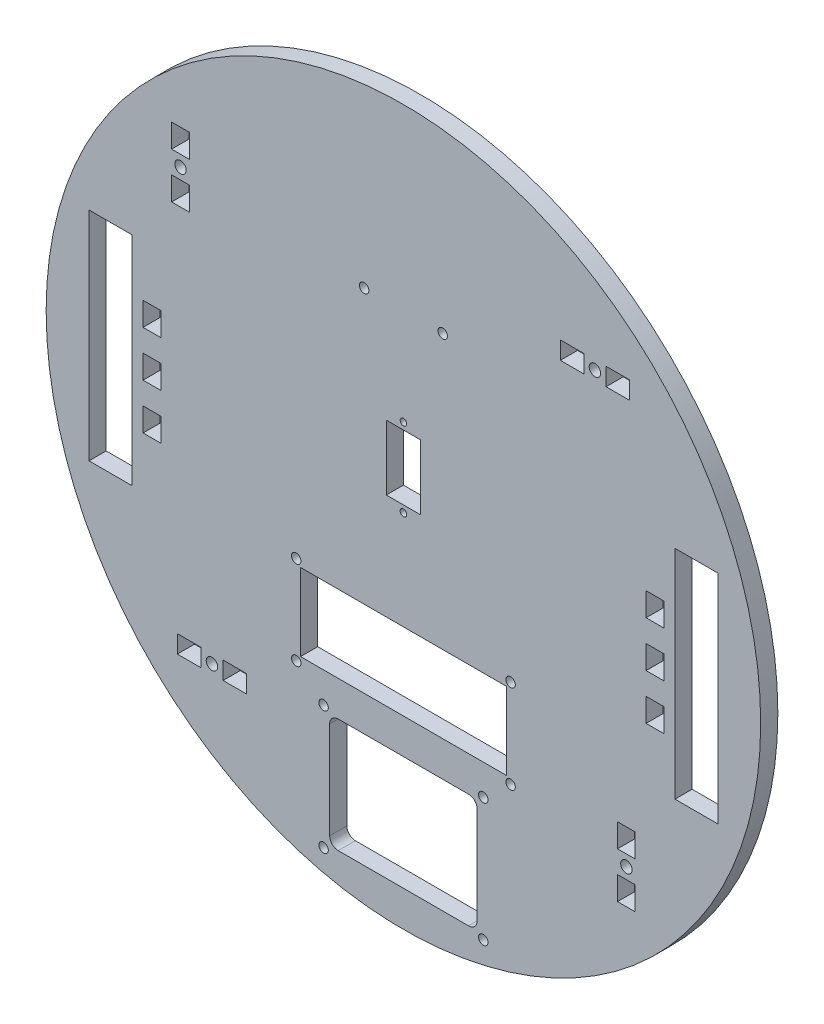
from build123d import *

# Parameters (mm, degrees)
ESQUISSE1_R                  = 125
BOSS_EXTRU_1_DEPTH           = 6
ESQUISSE2_W                  = 15
ESQUISSE2_H                  = 76
ENL_V_MAT_EXTRU_1_DEPTH      = 177.878489365
ESQUISSE3_R                  = 2
ESQUISSE3_W                  = 8.2
ESQUISSE3_H                  = 6.2
ENL_V_MAT_EXTRU_2_DEPTH      = 177.878489365
R_P_TITION_CIRCULAIRE1_COUNT = 4
ESQUISSE4_W                  = 6.2
ESQUISSE4_H                  = 8.2
ENL_V_MAT_EXTRU_3_DEPTH      = 177.878489365
ENL_V_MAT_EXTRU_4_REACH      = 178.878
ESQUISSE8_R                  = 1.65
ESQUISSE8_W                  = 72
ESQUISSE8_H                  = 27
ENL_V_MAT_EXTRU_5_REACH      = 178.878
ESQUISSE9_R                  = 1.65
ESQUISSE9_R_2                = 1.15
ESQUISSE9_W                  = 12
ESQUISSE9_H                  = 22.7


with BuildPart() as part:
    # Esquisse1 → Boss.-Extru.1 (new body)
    with BuildSketch(Plane.XY):
        Circle(ESQUISSE1_R)
    extrude(amount=BOSS_EXTRU_1_DEPTH)

    # Esquisse2 → Enlèv. mat.-Extru.1 (cut, through all)
    with BuildSketch(Plane.XY.offset(6)):
        with Locations((-102.5, 0)):
            Rectangle(ESQUISSE2_W, ESQUISSE2_H)
    enl_v_mat_extru_1 = extrude(amount=-ENL_V_MAT_EXTRU_1_DEPTH, mode=Mode.SUBTRACT)

    # Symétrie1: Enlèv. mat.-Extru.1 across plane
    add(enl_v_mat_extru_1.mirror(Plane(origin=(0, 0, 0), x_dir=(0, 0, 1), z_dir=(1, 0, 0))), mode=Mode.SUBTRACT)

    # Esquisse3 → Enlèv. mat.-Extru.2 (cut, through all)
    with BuildSketch(Plane(origin=(0, 0, 0), x_dir=(-1, 0, 0), z_dir=(0, 0, -1))):
        with Locations((-67, 78)):
            Circle(ESQUISSE3_R)
        with Locations((-75, 78)):
            Rectangle(ESQUISSE3_W, ESQUISSE3_H)
        with Locations((-59, 78)):
            Rectangle(ESQUISSE3_W, ESQUISSE3_H)
    enl_v_mat_extru_2 = extrude(amount=-ENL_V_MAT_EXTRU_2_DEPTH, mode=Mode.SUBTRACT)

    # Répétition circulaire1: Enlèv. mat.-Extru.2 ×4 about axis
    r_p_tition_circulaire1_axis = Axis((0, 0, -0.25), (0, 0, 1))
    for i in range(1, R_P_TITION_CIRCULAIRE1_COUNT):
        add(enl_v_mat_extru_2.rotate(r_p_tition_circulaire1_axis, i * 360 / R_P_TITION_CIRCULAIRE1_COUNT), mode=Mode.SUBTRACT)

    # Esquisse4 → Enlèv. mat.-Extru.3 (cut, through all)
    with BuildSketch(Plane(origin=(0, 0, 0), x_dir=(-1, 0, 0), z_dir=(0, 0, -1))):
        with Locations((88, 16)):
            Rectangle(ESQUISSE4_W, ESQUISSE4_H)
        with Locations((88, -16)):
            Rectangle(ESQUISSE4_W, ESQUISSE4_H)
        with Locations((88, 0)):
            Rectangle(ESQUISSE4_W, ESQUISSE4_H)
    enl_v_mat_extru_3 = extrude(amount=-ENL_V_MAT_EXTRU_3_DEPTH, mode=Mode.SUBTRACT)

    # Symétrie2: Enlèv. mat.-Extru.3 across plane
    add(enl_v_mat_extru_3.mirror(Plane(origin=(0, 0, 0), x_dir=(0, 0, 1), z_dir=(1, 0, 0))), mode=Mode.SUBTRACT)

    # Esquisse8 → Enlèv. mat.-Extru.4 (cut, up to next)
    with BuildSketch(Plane.XY.offset(6), mode=Mode.PRIVATE) as enl_v_mat_extru_4_sk1:
        with Locations((-37.5, -31.305965203)):
            Circle(ESQUISSE8_R)
    enl_v_mat_extru_4_tool1 = extrude(enl_v_mat_extru_4_sk1.sketch, amount=-ENL_V_MAT_EXTRU_4_REACH, mode=Mode.PRIVATE) & part.part
    # Esquisse8 → Enlèv. mat.-Extru.4 (cut, up to next)
    with BuildSketch(Plane.XY.offset(6), mode=Mode.PRIVATE) as enl_v_mat_extru_4_sk2:
        with Locations((37.5, -31.305965203)):
            Circle(ESQUISSE8_R)
    enl_v_mat_extru_4_tool2 = extrude(enl_v_mat_extru_4_sk2.sketch, amount=-ENL_V_MAT_EXTRU_4_REACH, mode=Mode.PRIVATE) & part.part
    # Esquisse8 → Enlèv. mat.-Extru.4 (cut, up to next)
    with BuildSketch(Plane.XY.offset(6), mode=Mode.PRIVATE) as enl_v_mat_extru_4_sk3:
        with Locations((37.5, -62.305965203)):
            Circle(ESQUISSE8_R)
    enl_v_mat_extru_4_tool3 = extrude(enl_v_mat_extru_4_sk3.sketch, amount=-ENL_V_MAT_EXTRU_4_REACH, mode=Mode.PRIVATE) & part.part
    # Esquisse8 → Enlèv. mat.-Extru.4 (cut, up to next)
    with BuildSketch(Plane.XY.offset(6), mode=Mode.PRIVATE) as enl_v_mat_extru_4_sk4:
        with Locations((-37.5, -62.305965203)):
            Circle(ESQUISSE8_R)
    enl_v_mat_extru_4_tool4 = extrude(enl_v_mat_extru_4_sk4.sketch, amount=-ENL_V_MAT_EXTRU_4_REACH, mode=Mode.PRIVATE) & part.part
    # Esquisse8 → Enlèv. mat.-Extru.4 (cut, up to next)
    with BuildSketch(Plane.XY.offset(6), mode=Mode.PRIVATE) as enl_v_mat_extru_4_sk5:
        with Locations((-27.94, -70.967629177)):
            Circle(ESQUISSE8_R)
    enl_v_mat_extru_4_tool5 = extrude(enl_v_mat_extru_4_sk5.sketch, amount=-ENL_V_MAT_EXTRU_4_REACH, mode=Mode.PRIVATE) & part.part
    # Esquisse8 → Enlèv. mat.-Extru.4 (cut, up to next)
    with BuildSketch(Plane.XY.offset(6), mode=Mode.PRIVATE) as enl_v_mat_extru_4_sk6:
        with Locations((27.94, -70.967629177)):
            Circle(ESQUISSE8_R)
    enl_v_mat_extru_4_tool6 = extrude(enl_v_mat_extru_4_sk6.sketch, amount=-ENL_V_MAT_EXTRU_4_REACH, mode=Mode.PRIVATE) & part.part
    # Esquisse8 → Enlèv. mat.-Extru.4 (cut, up to next)
    with BuildSketch(Plane.XY.offset(6), mode=Mode.PRIVATE) as enl_v_mat_extru_4_sk7:
        with Locations((27.94, -114.147629177)):
            Circle(ESQUISSE8_R)
    enl_v_mat_extru_4_tool7 = extrude(enl_v_mat_extru_4_sk7.sketch, amount=-ENL_V_MAT_EXTRU_4_REACH, mode=Mode.PRIVATE) & part.part
    # Esquisse8 → Enlèv. mat.-Extru.4 (cut, up to next)
    with BuildSketch(Plane.XY.offset(6), mode=Mode.PRIVATE) as enl_v_mat_extru_4_sk8:
        with Locations((-27.94, -114.147629177)):
            Circle(ESQUISSE8_R)
    enl_v_mat_extru_4_tool8 = extrude(enl_v_mat_extru_4_sk8.sketch, amount=-ENL_V_MAT_EXTRU_4_REACH, mode=Mode.PRIVATE) & part.part
    # Esquisse8 → Enlèv. mat.-Extru.4 (cut, up to next)
    with BuildSketch(Plane.XY.offset(6), mode=Mode.PRIVATE) as enl_v_mat_extru_4_sk9:
        with Locations((0, -46.805965203)):
            Rectangle(ESQUISSE8_W, ESQUISSE8_H)
    enl_v_mat_extru_4_tool9 = extrude(enl_v_mat_extru_4_sk9.sketch, amount=-ENL_V_MAT_EXTRU_4_REACH, mode=Mode.PRIVATE) & part.part
    # Esquisse8 → Enlèv. mat.-Extru.4 (cut, up to next)
    with BuildSketch(Plane.XY.offset(6), mode=Mode.PRIVATE) as enl_v_mat_extru_4_sk10:
        with BuildLine():
            Line((-22.804705882, -112.497629177), (22.804705882, -112.497629177))
            ThreePointArc((22.804705882, -112.497629177), (24.926026226, -111.618949521), (25.804705882, -109.497629177))
            Line((25.804705882, -109.497629177), (25.804705882, -75.617629177))
            ThreePointArc((25.804705882, -75.617629177), (24.926026226, -73.496308834), (22.804705882, -72.617629177))
            Line((22.804705882, -72.617629177), (-22.804705882, -72.617629177))
            ThreePointArc((-22.804705882, -72.617629177), (-24.926026226, -73.496308834), (-25.804705882, -75.617629177))
            Line((-25.804705882, -75.617629177), (-25.804705882, -109.497629177))
            ThreePointArc((-25.804705882, -109.497629177), (-24.926026226, -111.618949521), (-22.804705882, -112.497629177))
        make_face()
    enl_v_mat_extru_4_tool10 = extrude(enl_v_mat_extru_4_sk10.sketch, amount=-ENL_V_MAT_EXTRU_4_REACH, mode=Mode.PRIVATE) & part.part
    add(enl_v_mat_extru_4_tool1.solids().sort_by_distance((-37.5, -31.305965, 6))[0], mode=Mode.SUBTRACT)
    add(enl_v_mat_extru_4_tool2.solids().sort_by_distance((37.5, -31.305965, 6))[0], mode=Mode.SUBTRACT)
    add(enl_v_mat_extru_4_tool3.solids().sort_by_distance((37.5, -62.305965, 6))[0], mode=Mode.SUBTRACT)
    add(enl_v_mat_extru_4_tool4.solids().sort_by_distance((-37.5, -62.305965, 6))[0], mode=Mode.SUBTRACT)
    add(enl_v_mat_extru_4_tool5.solids().sort_by_distance((-27.94, -70.967629, 6))[0], mode=Mode.SUBTRACT)
    add(enl_v_mat_extru_4_tool6.solids().sort_by_distance((27.94, -70.967629, 6))[0], mode=Mode.SUBTRACT)
    add(enl_v_mat_extru_4_tool7.solids().sort_by_distance((27.94, -114.147629, 6))[0], mode=Mode.SUBTRACT)
    add(enl_v_mat_extru_4_tool8.solids().sort_by_distance((-27.94, -114.147629, 6))[0], mode=Mode.SUBTRACT)
    add(enl_v_mat_extru_4_tool9.solids().sort_by_distance((0, -46.805965, 6))[0], mode=Mode.SUBTRACT)
    add(enl_v_mat_extru_4_tool10.solids().sort_by_distance((0, -92.557629, 6))[0], mode=Mode.SUBTRACT)

    # Esquisse9 → Enlèv. mat.-Extru.5 (cut, up to next)
    with BuildSketch(Plane.XY.offset(6), mode=Mode.PRIVATE) as enl_v_mat_extru_5_sk1:
        with Locations((-13.75, 62.5)):
            Circle(ESQUISSE9_R)
    enl_v_mat_extru_5_tool1 = extrude(enl_v_mat_extru_5_sk1.sketch, amount=-ENL_V_MAT_EXTRU_5_REACH, mode=Mode.PRIVATE) & part.part
    # Esquisse9 → Enlèv. mat.-Extru.5 (cut, up to next)
    with BuildSketch(Plane.XY.offset(6), mode=Mode.PRIVATE) as enl_v_mat_extru_5_sk2:
        with Locations((13.75, 62.5)):
            Circle(ESQUISSE9_R)
    enl_v_mat_extru_5_tool2 = extrude(enl_v_mat_extru_5_sk2.sketch, amount=-ENL_V_MAT_EXTRU_5_REACH, mode=Mode.PRIVATE) & part.part
    # Esquisse9 → Enlèv. mat.-Extru.5 (cut, up to next)
    with BuildSketch(Plane.XY.offset(6), mode=Mode.PRIVATE) as enl_v_mat_extru_5_sk3:
        with Locations((0, 28.75)):
            Circle(ESQUISSE9_R_2)
    enl_v_mat_extru_5_tool3 = extrude(enl_v_mat_extru_5_sk3.sketch, amount=-ENL_V_MAT_EXTRU_5_REACH, mode=Mode.PRIVATE) & part.part
    # Esquisse9 → Enlèv. mat.-Extru.5 (cut, up to next)
    with BuildSketch(Plane.XY.offset(6), mode=Mode.PRIVATE) as enl_v_mat_extru_5_sk4:
        with Locations((0, 1.25)):
            Circle(ESQUISSE9_R_2)
    enl_v_mat_extru_5_tool4 = extrude(enl_v_mat_extru_5_sk4.sketch, amount=-ENL_V_MAT_EXTRU_5_REACH, mode=Mode.PRIVATE) & part.part
    # Esquisse9 → Enlèv. mat.-Extru.5 (cut, up to next)
    with BuildSketch(Plane.XY.offset(6), mode=Mode.PRIVATE) as enl_v_mat_extru_5_sk5:
        with Locations((0, 15)):
            Rectangle(ESQUISSE9_W, ESQUISSE9_H)
    enl_v_mat_extru_5_tool5 = extrude(enl_v_mat_extru_5_sk5.sketch, amount=-ENL_V_MAT_EXTRU_5_REACH, mode=Mode.PRIVATE) & part.part
    add(enl_v_mat_extru_5_tool1.solids().sort_by_distance((-13.75, 62.5, 6))[0], mode=Mode.SUBTRACT)
    add(enl_v_mat_extru_5_tool2.solids().sort_by_distance((13.75, 62.5, 6))[0], mode=Mode.SUBTRACT)
    add(enl_v_mat_extru_5_tool3.solids().sort_by_distance((0, 28.75, 6))[0], mode=Mode.SUBTRACT)
    add(enl_v_mat_extru_5_tool4.solids().sort_by_distance((0, 1.25, 6))[0], mode=Mode.SUBTRACT)
    add(enl_v_mat_extru_5_tool5.solids().sort_by_distance((0, 15, 6))[0], mode=Mode.SUBTRACT)


solid = part.part
